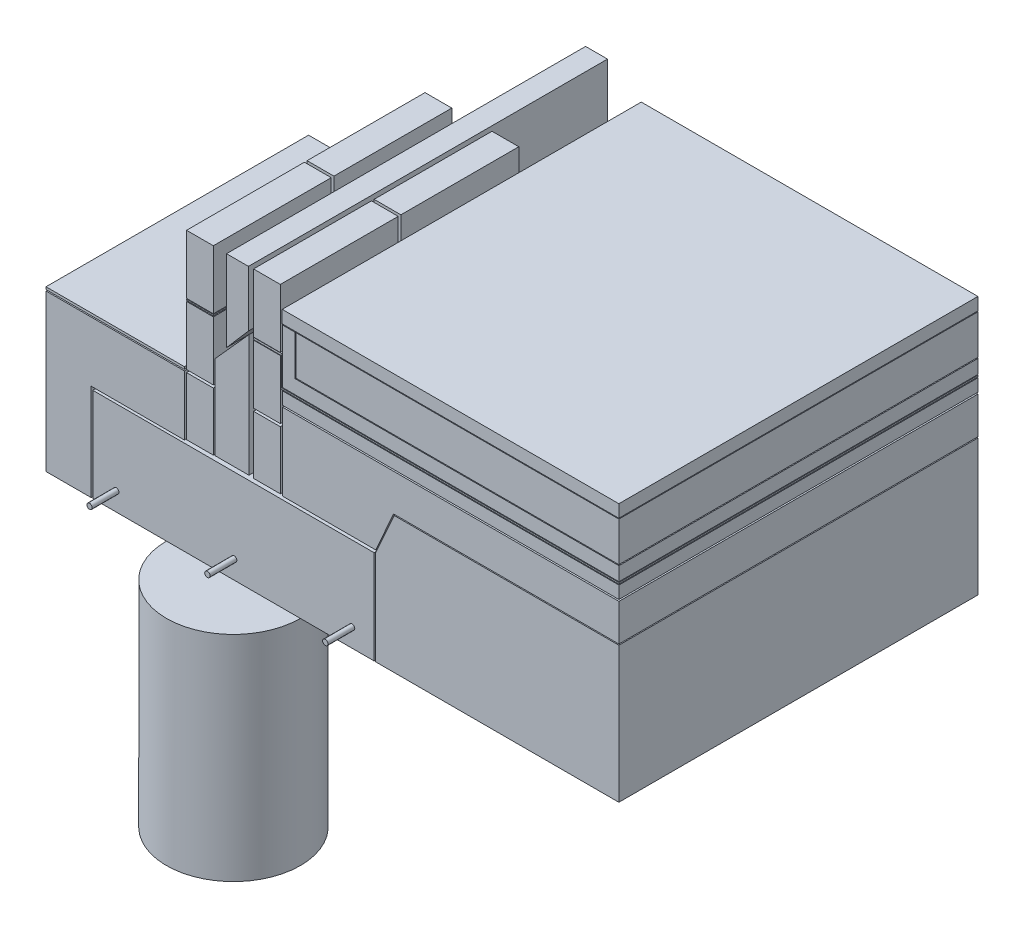
from build123d import *

# Parameters (mm, degrees)
SKETCH1_W        = 1050
SKETCH1_H        = 350
EXTRUDE1_DEPTH   = 1500
SKETCH2_W        = 100
SKETCH2_H        = 216.893893569
EXTRUDE2_DEPTH   = 440
EXTRUDE2_2_DEPTH = 440
SKETCH3_W        = 440
SKETCH3_H        = 220
EXTRUDE3_DEPTH   = 100
EXTRUDE3_2_DEPTH = 100
SKETCH4_W        = 440
SKETCH4_H        = 220
EXTRUDE4_DEPTH   = 100
EXTRUDE4_2_DEPTH = 100
SKETCH6_W        = 215
SKETCH6_H        = 220
EXTRUDE6_DEPTH   = 100
SKETCH6_W_2      = 445.705034037
EXTRUDE6_2_DEPTH = 100
SKETCH6_W_3      = 440
EXTRUDE6_3_DEPTH = 100
SKETCH7_W        = 215
SKETCH7_H        = 220
EXTRUDE7_DEPTH   = 100
SKETCH7_W_2      = 445.705034037
EXTRUDE7_2_DEPTH = 100
SKETCH7_W_3      = 440
EXTRUDE7_3_DEPTH = 100
SKETCH8_W        = 440
SKETCH8_H        = 220
EXTRUDE8_DEPTH   = 100
EXTRUDE8_2_DEPTH = 100
SKETCH9_W        = 440
SKETCH9_H        = 220
EXTRUDE9_DEPTH   = 100
EXTRUDE9_2_DEPTH = 100
SKETCH10_R       = 10
EXTRUDE10_DEPTH  = 100
EXTRUDE11_DEPTH  = 1340
EXTRUDE12_DEPTH  = 1340
EXTRUDE13_DEPTH  = 1340
SKETCH26_W       = 1256.088144014
SKETCH26_H       = 46.690394956
EXTRUDE24_DEPTH  = 1340
EXTRUDE25_DEPTH  = 1340
EXTRUDE26_DEPTH  = 1340
SKETCH29_W       = 1205.291477373
SKETCH29_H       = 147.133675666
EXTRUDE27_DEPTH  = 1340
SKETCH30_W       = 1256.417531195
SKETCH30_H       = 46.85268677
EXTRUDE28_DEPTH  = 1340
SKETCH19_W       = 100.016924429
SKETCH19_H       = 4.415976872
EXTRUDE19_DEPTH  = 1120.705034
SKETCH20_R       = 250
EXTRUDE20_DEPTH  = 799
EXTRUDE21_DEPTH  = 980
EXTRUDE22_DEPTH  = 1340
SKETCH25_W       = 516.397529347
SKETCH25_H       = 9.115315182
EXTRUDE23_DEPTH  = 980


with BuildPart() as part:
    # Sketch1 → Extrude1 (new body)
    with BuildSketch(Plane.XY):
        with Locations((-525, 175)):
            Rectangle(SKETCH1_W, SKETCH1_H)
    extrude(amount=-EXTRUDE1_DEPTH)

    # Sketch10 → Extrude10 (add)
    with BuildSketch(Plane.XY):
        with Locations((-962.14462561, 68.901890749)):
            Circle(SKETCH10_R)
        with Locations((-522.14462561, 68.901890749)):
            Circle(SKETCH10_R)
        with Locations((-82.14462561, 68.901890749)):
            Circle(SKETCH10_R)
    extrude(amount=EXTRUDE10_DEPTH)

    # Sketch20 → Extrude20 (add)
    with BuildSketch(Plane.XZ):
        with Locations((-525, 0)):
            Circle(SKETCH20_R)
        with Locations((-525, -1500)):
            Circle(SKETCH20_R)
    extrude(amount=EXTRUDE20_DEPTH)


with BuildPart() as body_2:
    # Sketch2 → Extrude2 (new body)
    with BuildSketch(Plane.XY):
        with Locations((-650, 473.646207299)):
            Rectangle(SKETCH2_W, SKETCH2_H)
    extrude(amount=-EXTRUDE2_DEPTH)


with BuildPart() as body_3:
    # Sketch2 → Extrude2 2 (new body)
    with BuildSketch(Plane.XY):
        with Locations((-400, 473.646207299)):
            Rectangle(SKETCH2_W, SKETCH2_H)
    extrude(amount=-EXTRUDE2_2_DEPTH)


with BuildPart() as body_4:
    # Sketch3 → Extrude3 (new body)
    with BuildSketch(Plane.ZY.offset(700)):
        with Locations((-670, 472.093154083)):
            Rectangle(SKETCH3_W, SKETCH3_H)
    extrude(amount=-EXTRUDE3_DEPTH)


with BuildPart() as body_5:
    # Sketch3 → Extrude3 2 (new body)
    with BuildSketch(Plane.ZY.offset(700)):
        with Locations((-1120, 472.093154083)):
            Rectangle(SKETCH3_W, SKETCH3_H)
    extrude(amount=-EXTRUDE3_2_DEPTH)


with BuildPart() as body_6:
    # Sketch4 → Extrude4 (new body)
    with BuildSketch(Plane(origin=(-350, 0, 0), x_dir=(0, 0, -1), z_dir=(1, 0, 0))):
        with Locations((670, 472.093154083)):
            Rectangle(SKETCH4_W, SKETCH4_H)
    extrude(amount=-EXTRUDE4_DEPTH)


with BuildPart() as body_7:
    # Sketch4 → Extrude4 2 (new body)
    with BuildSketch(Plane(origin=(-350, 0, 0), x_dir=(0, 0, -1), z_dir=(1, 0, 0))):
        with Locations((1120, 472.093154083)):
            Rectangle(SKETCH4_W, SKETCH4_H)
    extrude(amount=-EXTRUDE4_2_DEPTH)


with BuildPart() as body_8:
    # Sketch6 → Extrude6 (new body)
    with BuildSketch(Plane.ZY.offset(700)):
        with Locations((-107.5, 702.093154083)):
            Rectangle(SKETCH6_W, SKETCH6_H)
    extrude(amount=-EXTRUDE6_DEPTH)


with BuildPart() as body_9:
    # Sketch6 → Extrude6 2 (new body)
    with BuildSketch(Plane.ZY.offset(700)):
        with Locations((-447.852517019, 702.093154083)):
            Rectangle(SKETCH6_W_2, SKETCH6_H)
    extrude(amount=-EXTRUDE6_2_DEPTH)


with BuildPart() as body_10:
    # Sketch6 → Extrude6 3 (new body)
    with BuildSketch(Plane.ZY.offset(700)):
        with Locations((-900.705034037, 702.093154083)):
            Rectangle(SKETCH6_W_3, SKETCH6_H)
    extrude(amount=-EXTRUDE6_3_DEPTH)


with BuildPart() as body_11:
    # Sketch7 → Extrude7 (new body)
    with BuildSketch(Plane(origin=(-350, 0, 0), x_dir=(0, 0, -1), z_dir=(1, 0, 0))):
        with Locations((107.5, 702.093154083)):
            Rectangle(SKETCH7_W, SKETCH7_H)
    extrude(amount=-EXTRUDE7_DEPTH)


with BuildPart() as body_12:
    # Sketch7 → Extrude7 2 (new body)
    with BuildSketch(Plane(origin=(-350, 0, 0), x_dir=(0, 0, -1), z_dir=(1, 0, 0))):
        with Locations((447.852517019, 702.093154083)):
            Rectangle(SKETCH7_W_2, SKETCH7_H)
    extrude(amount=-EXTRUDE7_2_DEPTH)


with BuildPart() as body_13:
    # Sketch7 → Extrude7 3 (new body)
    with BuildSketch(Plane(origin=(-350, 0, 0), x_dir=(0, 0, -1), z_dir=(1, 0, 0))):
        with Locations((900.705034037, 702.093154083)):
            Rectangle(SKETCH7_W_3, SKETCH7_H)
    extrude(amount=-EXTRUDE7_3_DEPTH)


with BuildPart() as body_14:
    # Sketch8 → Extrude8 (new body)
    with BuildSketch(Plane.ZY.offset(700)):
        with Locations((-220, 932.093154083)):
            Rectangle(SKETCH8_W, SKETCH8_H)
    extrude(amount=-EXTRUDE8_DEPTH)


with BuildPart() as body_15:
    # Sketch8 → Extrude8 2 (new body)
    with BuildSketch(Plane.ZY.offset(700)):
        with Locations((-670, 932.093154083)):
            Rectangle(SKETCH8_W, SKETCH8_H)
    extrude(amount=-EXTRUDE8_2_DEPTH)


with BuildPart() as body_16:
    # Sketch9 → Extrude9 (new body)
    with BuildSketch(Plane(origin=(-350, 0, 0), x_dir=(0, 0, -1), z_dir=(1, 0, 0))):
        with Locations((220, 932.093154083)):
            Rectangle(SKETCH9_W, SKETCH9_H)
    extrude(amount=-EXTRUDE9_DEPTH)


with BuildPart() as body_17:
    # Sketch9 → Extrude9 2 (new body)
    with BuildSketch(Plane(origin=(-350, 0, 0), x_dir=(0, 0, -1), z_dir=(1, 0, 0))):
        with Locations((670, 932.093154083)):
            Rectangle(SKETCH9_W, SKETCH9_H)
    extrude(amount=-EXTRUDE9_2_DEPTH)


with BuildPart() as body_18:
    # Sketch11 → Extrude11 (new body)
    with BuildSketch(Plane.XY):
        Polygon((-467.142623081, 366.760238591), (-467.142623081, 821.047790695), (-593.71305263, 680.021419663), (-593.71305263, 366.760238591), align=None)
    extrude(amount=-EXTRUDE11_DEPTH)


with BuildPart() as body_19:
    # Sketch12 → Extrude12 (new body)
    with BuildSketch(Plane.XY):
        Polygon((-468.887831959, 831.987849689), (-468.887831959, 1040.989689962), (-550.716667875, 1040.989689962), (-550.716667875, 737.60580318), align=None)
    extrude(amount=-EXTRUDE12_DEPTH)


with BuildPart() as body_20:
    # Sketch13 → Extrude13 (new body)
    with BuildSketch(Plane.XY):
        Polygon((6.53994331, 361.986236304), (72.372848708, 511.620468575), (913.666899137, 511.620468575), (913.666899137, 649.537526022), (-341.378323634, 649.537526022), (-341.378323634, 361.986236304), align=None)
    extrude(amount=-EXTRUDE13_DEPTH)


with BuildPart() as body_21:
    # Sketch26 → Extrude24 (new body)
    with BuildSketch(Plane(origin=(0, 0, -1340), x_dir=(-1, 0, 0), z_dir=(0, 0, -1))):
        with Locations((-285.62282713, 678.850982258)):
            Rectangle(SKETCH26_W, SKETCH26_H)
    extrude(amount=-EXTRUDE24_DEPTH)


with BuildPart() as body_22:
    # Sketch27 → Extrude25 (new body)
    with BuildSketch(Plane.XY):
        Polygon((-450.091665336, 821.098271696), (-344.221780668, 821.098271696), (-344.221780668, 710.279157377), (913.666899137, 710.279157377), (913.666899137, 705.18089352), (-347.773541074, 705.18089352), (-347.773541074, 814.031809157), (-450.091665336, 814.031809157), align=None)
    extrude(amount=-EXTRUDE25_DEPTH)


with BuildPart() as body_23:
    # Sketch28 → Extrude26 (new body)
    with BuildSketch(Plane.XY):
        Polygon((-342.295730534, 713.080654362), (-342.295730534, 914.99424937), (-294.853367914, 914.99424937), (-294.853367914, 764.921576876), (913.875507496, 764.921576876), (913.875507496, 713.080654362), align=None)
    extrude(amount=-EXTRUDE26_DEPTH)


with BuildPart() as body_24:
    # Sketch29 → Extrude27 (new body)
    with BuildSketch(Plane.XY):
        with Locations((310.896318694, 841.76418087)):
            Rectangle(SKETCH29_W, SKETCH29_H)
    extrude(amount=-EXTRUDE27_DEPTH)


with BuildPart() as body_25:
    # Sketch30 → Extrude28 (new body)
    with BuildSketch(Plane.XY):
        with Locations((285.333291784, 941.606691276)):
            Rectangle(SKETCH30_W, SKETCH30_H)
    extrude(amount=-EXTRUDE28_DEPTH)


with BuildPart() as body_26:
    # Sketch19 → Extrude19 (new body)
    with BuildSketch(Plane.XY):
        with Locations((-650.08879901, 817.553634615)):
            Rectangle(SKETCH19_W, SKETCH19_H)
    extrude(amount=-EXTRUDE19_DEPTH)


with BuildPart() as body_27:
    # Sketch21 → Extrude21 (new body)
    with BuildSketch(Plane.XY):
        Polygon((-1055.858657452, 0), (-1055.858657452, 360.225541847), (-708.103145051, 360.225541847), (-708.103145051, 583.456915126), (-1224.500674398, 583.456915126), (-1224.500674398, 0), align=None)
    extrude(amount=-EXTRUDE21_DEPTH)


with BuildPart() as body_28:
    # Sketch24 → Extrude22 (new body)
    with BuildSketch(Plane.XY):
        Polygon((74.984037107, 507.583799669), (4.694830513, 349.63506531), (4.694830513, 0), (913.528796181, 0), (913.528796181, 507.583799669), align=None)
    extrude(amount=-EXTRUDE22_DEPTH)


with BuildPart() as body_29:
    # Sketch25 → Extrude23 (new body)
    with BuildSketch(Plane.XY):
        with Locations((-966.301909725, 592.714818423)):
            Rectangle(SKETCH25_W, SKETCH25_H)
    extrude(amount=-EXTRUDE23_DEPTH)


solid = Compound([part.part, body_2.part, body_3.part, body_4.part, body_5.part, body_6.part, body_7.part, body_8.part, body_9.part, body_10.part, body_11.part, body_12.part, body_13.part, body_14.part, body_15.part, body_16.part, body_17.part, body_18.part, body_19.part, body_20.part, body_21.part, body_22.part, body_23.part, body_24.part, body_25.part, body_26.part, body_27.part, body_28.part, body_29.part])
